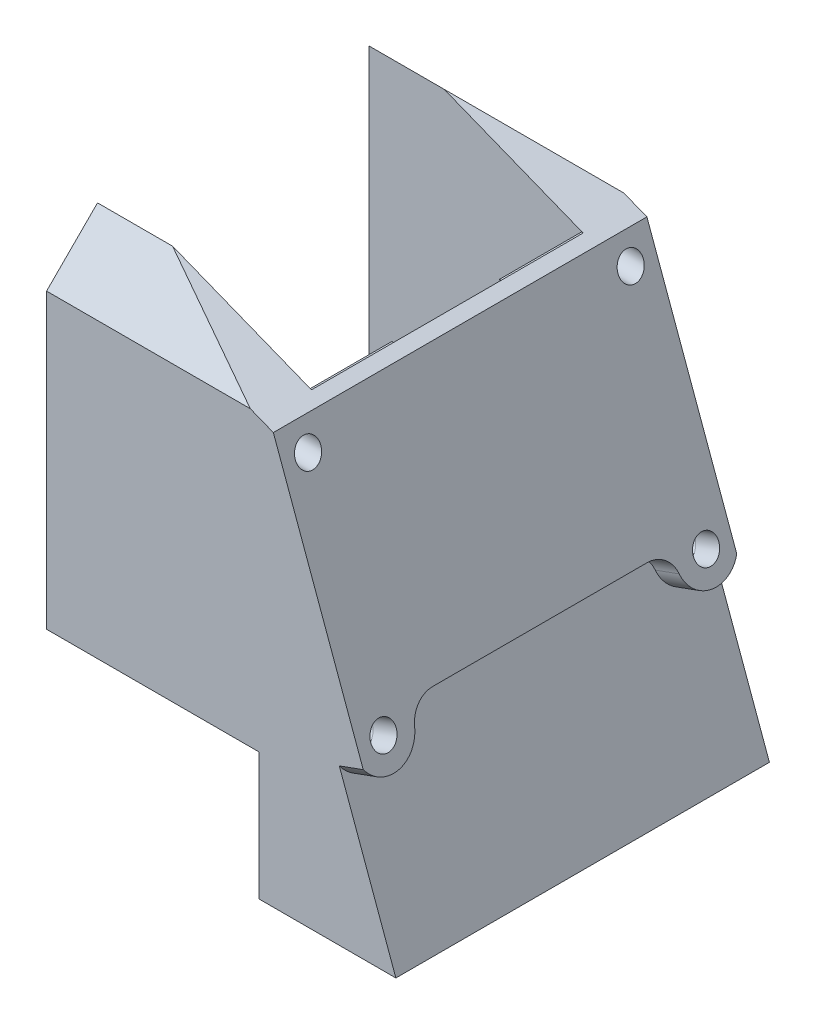
from build123d import *

# Parameters (mm, degrees)
BOSS_EXTRUDE1_DEPTH = 6
CUT_EXTRUDE1_DEPTH  = 59.057322490699136
BOSS_EXTRUDE2_DEPTH = 32
BOSS_EXTRUDE3_DEPTH = 0.2
BOSS_EXTRUDE4_DEPTH = 15
BOSS_EXTRUDE5_DEPTH = 6
CUT_EXTRUDE2_DEPTH  = 70.12779972477816
SKETCH8_R           = 1.5000000000000042
SKETCH8_R_2         = 1.5000000000000018
CUT_EXTRUDE3_DEPTH  = 70.12779972477817
SKETCH9_W           = 2.49999999999999
SKETCH9_H           = 5.999999999999993
BOSS_EXTRUDE6_DEPTH = 15
CUT_EXTRUDE4_DEPTH  = 3
BOSS_EXTRUDE7_DEPTH = 3
FILLET1_R           = 3


with BuildPart() as part:
    # Sketch1 → Boss-Extrude1 (new body)
    with BuildSketch(Plane.XY):
        Polygon((-25, 22.000000000000007), (1.7101007166283717, 11.425886468780801), (19.33568195921926, -36.99999999999998), (2.500000000000002, -36.999999999999986), (2.500000000000002, -21.999999999999986), (-25.000000000000004, -21.99999999999999), align=None)
    extrude(amount=BOSS_EXTRUDE1_DEPTH)

    # Sketch2 → Cut-Extrude1 (cut, through all)
    with BuildSketch(Plane.ZY.offset(25.000000000000004)):
        Polygon((-4.44e-15, 18.499999999999993), (5.999999999999988, 12.499999999999988), (5.999999999999991, 22.000000000000007), (0, 22.000000000000004), align=None)
    extrude(amount=-CUT_EXTRUDE1_DEPTH, mode=Mode.SUBTRACT)

    # Sketch3 → Boss-Extrude2 (add)
    with BuildSketch(Plane(origin=(0, 0, 0), x_dir=(-1, 0, 0), z_dir=(0, 0, -1))):
        Polygon((-1.7101007166283715, 11.425886468780803), (-19.33568195921926, -36.99999999999998), (-2.500000000000002, -36.999999999999986), (-2.500000000000002, -21.999999999999986), (0, -21.999999999999986), (-9.2e-16, 1.3500000000000014), (-0.2, 1.3499999999999996), (-0.2, 12.023711860403642), align=None)
    extrude(amount=BOSS_EXTRUDE2_DEPTH)

    # Sketch4 → Boss-Extrude3 (add)
    with BuildSketch(Plane.ZY.offset(-0.2)):
        with BuildLine():
            Line((-32, 12.02371186040364), (-32, 1.3499999999999996))
            Line((-32, 1.3499999999999996), (-19.46806862677186, 1.3499999999999996))
            ThreePointArc((-19.468068626771874, 1.3499999999999552), (-23.244240803514778, 6.058100110538283), (-22.32927664622476, 12.023711860403747))
            Line((-22.32927664622472, 12.02371186040364), (-32, 12.02371186040364))
        make_face()
        with BuildLine():
            ThreePointArc((-8.499999999999993, 7.999999999999998), (-9.586712438195622, 4.111588672786104), (-12.531931373228087, 1.3499999999999694))
            Line((-12.53193137322809, 1.3499999999999999), (0, 1.3499999999999999))
            Line((0, 1.3499999999999979), (0, 12.023711860403642))
            Line((0, 12.02371186040364), (-9.670723353775251, 12.02371186040364))
            ThreePointArc((-9.67072335377522, 12.023711860403733), (-8.798626004480603, 10.09528341201306), (-8.499999999999993, 8))
        make_face()
    extrude(amount=BOSS_EXTRUDE3_DEPTH)

    # Sketch5 → Boss-Extrude4 (add)
    with BuildSketch(Plane.XZ.offset(21.999999999999986)):
        with BuildLine():
            Line((-1.86e-15, 0), (-1.86e-15, -6.333801512904159))
            ThreePointArc((-1.1013e-13, -6.333801512904192), (1.8581867686024491, -9.836881046371968), (2.4999999999999964, -13.750000014767066))
            Line((2.4999999999999973, -13.750000014767064), (2.4999999999999973, 6.000000000000006))
            Line((2.4999999999999973, 6.000000000000006), (-1.8e-15, 6))
            Line((-1.8e-15, 6), (-1.86e-15, 0))
        make_face()
        with BuildLine():
            Line((-1.86e-15, -21.166198487095418), (-1.86e-15, -32))
            Line((-1.78e-15, -32), (2.4999999999999973, -32))
            Line((2.4999999999999973, -32), (2.4999999999999973, -13.750000014767064))
            ThreePointArc((2.4999999999999964, -13.750000014767066), (1.8581867638853513, -17.6631189676212), (1.4744e-13, -21.166198487095464))
        make_face()
    extrude(amount=BOSS_EXTRUDE4_DEPTH)

    # Sketch6 → Boss-Extrude5 (add)
    with BuildSketch(Plane(origin=(2.66e-15, 0, -32), x_dir=(-1, 0, -8e-17), z_dir=(8e-17, 0, -1))):
        Polygon((25, 22.000000000000007), (-1.7101007166283717, 11.425886468780801), (-19.33568195921926, -36.99999999999998), (-2.500000000000002, -36.999999999999986), (-2.500000000000002, -21.999999999999986), (25.000000000000004, -21.99999999999999), align=None)
    extrude(amount=BOSS_EXTRUDE5_DEPTH)

    # Sketch7 → Cut-Extrude2 (cut, through all)
    with BuildSketch(Plane.ZY.offset(25.000000000000004)):
        Polygon((-38.00000000000001, 22.000000000000004), (-32, 22.000000000000004), (-32, 18.499999999999982), (-38.00000000000001, 12.49999999999995), align=None)
    extrude(amount=-CUT_EXTRUDE2_DEPTH, mode=Mode.SUBTRACT)

    # Sketch8 → Cut-Extrude3 (cut, through all)
    with BuildSketch(Plane.ZY.offset(25.000000000000004)):
        with Locations((-34.99999999999999, 8.428932188134494)):
            Circle(SKETCH8_R)
        with Locations((-34.99999999999999, -17.000000000000004)):
            Circle(SKETCH8_R)
        with Locations((3.0000000000000027, -16.99999999999999)):
            Circle(SKETCH8_R_2)
        with Locations((2.9999999999999956, 8.428932188134505)):
            Circle(SKETCH8_R_2)
    extrude(amount=-CUT_EXTRUDE3_DEPTH, mode=Mode.SUBTRACT)

    # Sketch9 → Boss-Extrude6 (add)
    with BuildSketch(Plane.XZ.offset(36.999999999999986)):
        with Locations((1.249999999999995, -35)):
            Rectangle(SKETCH9_W, SKETCH9_H)
    extrude(amount=-BOSS_EXTRUDE6_DEPTH)

    # Sketch10 → Cut-Extrude4 (cut)
    with BuildSketch(Plane(origin=(5.182266059796382, 1.8861905918139033, 0), x_dir=(0, 0, -1), z_dir=(0.939692620785907, 0.34202014332567265, 0))):
        Polygon((37.99999999999999, -41.38181968407034), (37.99999999999999, -17.381819684070333), (-5.999999999999991, -17.381819684070337), (-6.00000000000001, -41.38181968407034), align=None)
    extrude(amount=-CUT_EXTRUDE4_DEPTH, mode=Mode.SUBTRACT)

    # Sketch11 → Boss-Extrude7 (add)
    # profile 1 of 2: a face of its own
    with BuildSketch(Plane(origin=(2.363188197438662, 0.8601301618368854, 0), x_dir=(0, 0, -1), z_dir=(0.939692620785907, 0.3420201433256727, 0))):
        with BuildLine():
            ThreePointArc((0.499999999999996, -19.00635353175345), (0.39856604189581324, -18.16984360421368), (0.10014350921565462, -17.38181968407036))
            Line((0.10014350921566262, -17.38181968407034), (-5.999999999999993, -17.38181968407034))
            Line((-5.999999999999991, -17.38181968407034), (-5.999999999999994, -20.809129169485423))
            ThreePointArc((-6.000000000000014, -20.809129169485427), (-2.0645856533065285, -22.379037922561462), (0.499999999999996, -19.00635353175345))
        make_face()
        with BuildLine():
            add(Edge.make_bspline(
                [(-3.000000000000003, -17.410086873039575), (-5.598076211353321, -17.410086873039575), (-4.299038105676663, -19.804486861110384), (-3.0000000000000044, -22.198886849181193), (-1.7009618943233444, -19.804486861110384), (-0.4019237886466831, -17.410086873039578), (-3.0000000000000027, -17.410086873039575)],
                knots=[0, 0, 0, 2.0943951023931953, 2.0943951023931953, 4.1887902047863905, 4.1887902047863905, 6.283185307179586, 6.283185307179586, 6.283185307179586], degree=2, weights=[1, 0.5000000000000001, 1, 0.5000000000000001, 1, 0.5000000000000001, 1]))
        make_face(mode=Mode.SUBTRACT)
    # profile 2 of 2: a face of its own
    with BuildSketch(Plane(origin=(2.363188197438662, 0.8601301618368854, 0), x_dir=(0, 0, -1), z_dir=(0.939692620785907, 0.3420201433256727, 0))):
        with BuildLine():
            Line((37.99999999999999, -20.809129169485587), (37.99999999999999, -17.381819684070337))
            Line((37.99999999999999, -17.381819684070337), (31.899856490784423, -17.381819684070337))
            ThreePointArc((31.899856490784394, -17.38181968407025), (33.28561388310159, -22.057727032684816), (37.99999999999992, -20.80912916948557))
        make_face()
        with BuildLine():
            add(Edge.make_bspline(
                [(34.999999999999986, -17.41008687303959), (32.40192378864666, -17.41008687303959), (33.70096189432332, -19.8044868611104), (34.999999999999986, -22.198886849181218), (36.299038105676644, -19.804486861110405), (37.59807621135331, -17.410086873039592), (34.999999999999986, -17.41008687303959)],
                knots=[0, 0, 0, 2.0943951023931953, 2.0943951023931953, 4.1887902047863905, 4.1887902047863905, 6.283185307179586, 6.283185307179586, 6.283185307179586], degree=2, weights=[1, 0.5000000000000001, 1, 0.5000000000000001, 1, 0.5000000000000001, 1]))
        make_face(mode=Mode.SUBTRACT)
    extrude(amount=BOSS_EXTRUDE7_DEPTH)

    # Fillet1
    fillet1_edges = [part.edges().sort_by_distance(p)[0] for p in [
        (9.717659588224263, -14.960407316126739, -0.10014350921565796),
        (9.717659588224242, -14.960407316126686, -31.89985649078441),
    ]]
    fillet(fillet1_edges, radius=FILLET1_R)


solid = part.part
